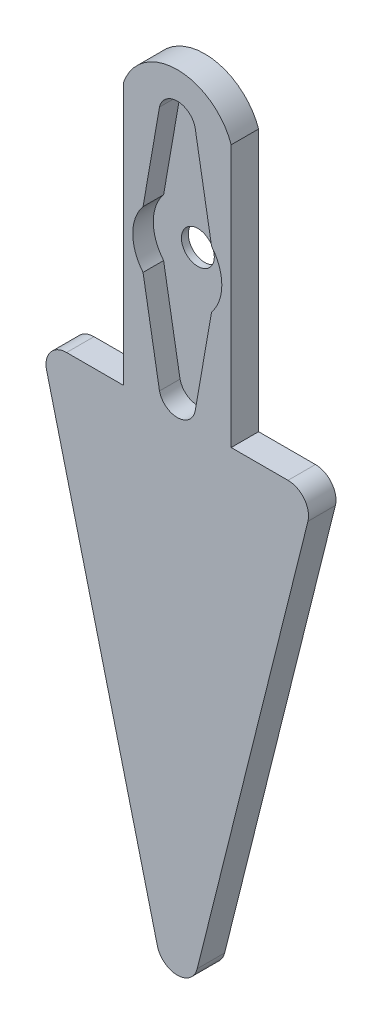
from build123d import *

# Parameters (mm, degrees)
EXTRUDE_1_DEPTH = 4
SKETCH_2_R      = 2.4
EXTRUDE_2_DEPTH = 1
FILLET_1_R      = 3


with BuildPart() as part:
    # 草圖1 → 填料-伸長1 (new body)
    with BuildSketch(Plane.XY):
        with BuildLine():
            Line((-7.867443673, 18.408334232), (-7.867443673, -19.856671438))
            Line((-7.867443673, -19.856671438), (-20, -19.856671438))
            Line((-20, -19.856671438), (0, -99.856671438))
            Line((0, -99.856671438), (20, -19.856671438))
            Line((20, -19.856671438), (7.867443673, -19.856671438))
            Line((7.867443673, -19.856671438), (7.867443673, 18.408334232))
            ThreePointArc((7.867443673, 18.408334232), (0, 23.981275915), (-7.867443673, 18.408334232))
        make_face()
        with BuildLine():
            ThreePointArc((-4.999271035, -4.154189345), (-6.5, 0), (-4.999271035, 4.154189345))
            Line((-4.999271035, 4.154189345), (-2.6, 17.94275172))
            ThreePointArc((-2.6, 17.94275172), (0, 20), (2.6, 17.94275172))
            Line((2.6, 17.94275172), (4.999271035, 4.154189345))
            ThreePointArc((4.999271035, 4.154189345), (6.5, 0), (4.999271035, -4.154189345))
            Line((4.999271035, -4.154189345), (2.6, -17.94275172))
            ThreePointArc((2.6, -17.94275172), (0, -20), (-2.6, -17.94275172))
            Line((-2.6, -17.94275172), (-4.999271035, -4.154189345))
        make_face(mode=Mode.SUBTRACT)
    extrude(amount=EXTRUDE_1_DEPTH)

    # 草圖2 → 填料-伸長2 (add)
    with BuildSketch(Plane.XY):
        with BuildLine():
            Line((-3.702325647, 20.172267208), (4.497563026, 20.172267208))
            ThreePointArc((4.497563026, 20.172267208), (6.068658829, 19.068237677), (7.032818959, 17.407629814))
            Line((7.032818959, 17.407629814), (7.032818959, -20.628324178))
            Line((7.032818959, -20.628324178), (-6.646673958, -20.628324178))
            Line((-6.646673958, -20.628324178), (-6.646673958, 17.471058727))
            ThreePointArc((-6.646673958, 17.471058727), (-5.621736824, 19.309156464), (-3.702325647, 20.172267208))
        make_face()
        Circle(SKETCH_2_R, mode=Mode.SUBTRACT)
    extrude(amount=EXTRUDE_2_DEPTH)

    # 圓角1
    fillet_1_edges = [part.edges().sort_by_distance(p)[0] for p in [
        (20, -19.856671438, 2),
        (0, -99.856671438, 2),
        (-20, -19.856671438, 2),
    ]]
    fillet(fillet_1_edges, radius=FILLET_1_R)


solid = part.part
